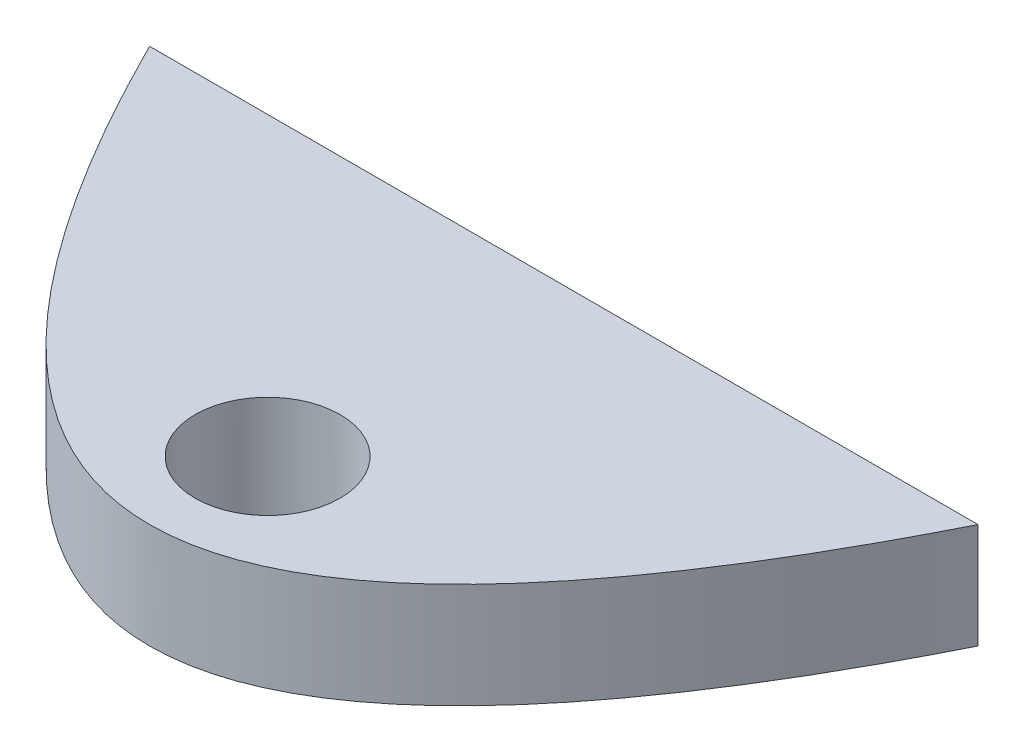
from build123d import *

# Parameters (mm, degrees)
BOSS_EXTRUDE1_DEPTH     = 300
SKETCH3_R               = 15.5
CUT_EXTRUDE1_DEPTH      = 23
CUT_EXTRUDE1_DEPTH_BACK = 23
SKETCH4_R               = 35
CUT_EXTRUDE3_DEPTH      = 300
SKETCH5_W               = 510.361760703
SKETCH5_H               = 258.349315351
SKETCH5_W_2             = 511.824115319
SKETCH5_H_2             = 70.193021529
CUT_EXTRUDE4_DEPTH      = 201.0000001


with BuildPart() as part:
    # Sketch1 → Boss-Extrude1 (new body)
    with BuildSketch(Plane(origin=(0, 0, 0), x_dir=(1, 0, 0), z_dir=(0, 1, 0))):
        with BuildLine():
            Line((-200, 1e-09), (200, 1e-09))
            add(Edge.make_bspline(
                [(-200, 1e-09), (0, -400.000000001), (200, 1e-09)],
                knots=[0.056028396, 0.056028396, 0.056028396, 0.943971604, 0.943971604, 0.943971604], degree=2))
        make_face()
    extrude(amount=BOSS_EXTRUDE1_DEPTH)

    # Sketch3 → Cut-Extrude1 (cut, two sides)
    with BuildSketch(Plane(origin=(0, 150, 0), x_dir=(1, 0, 0), z_dir=(0, 1, 0))) as cut_extrude1_sk:
        with Locations((0, -142.999999999)):
            Circle(SKETCH3_R)
    extrude(amount=CUT_EXTRUDE1_DEPTH, mode=Mode.SUBTRACT)
    extrude(cut_extrude1_sk.sketch, amount=-CUT_EXTRUDE1_DEPTH_BACK, mode=Mode.SUBTRACT)

    # Sketch4 → Cut-Extrude3 (cut)
    with BuildSketch(Plane(origin=(0, 173, 0), x_dir=(1, 0, 0), z_dir=(0, 1, 0))):
        with Locations((0, -142.999999999)):
            Circle(SKETCH4_R)
    cut_extrude3 = extrude(amount=CUT_EXTRUDE3_DEPTH, mode=Mode.SUBTRACT)

    # Mirror1: Cut-Extrude3 across plane
    add(cut_extrude3.mirror(Plane.ZX.offset(150)), mode=Mode.SUBTRACT)

    # Sketch5 → Cut-Extrude4 (cut, through all)
    with BuildSketch(Plane(origin=(0, 0, 0), x_dir=(-1, 0, 0), z_dir=(0, 0, -1))):
        with Locations((9.26157923, 225.974657676)):
            Rectangle(SKETCH5_W, SKETCH5_H)
        with Locations((5.118241153, 10.903489235)):
            Rectangle(SKETCH5_W_2, SKETCH5_H_2)
    extrude(amount=-CUT_EXTRUDE4_DEPTH, mode=Mode.SUBTRACT)


solid = part.part
